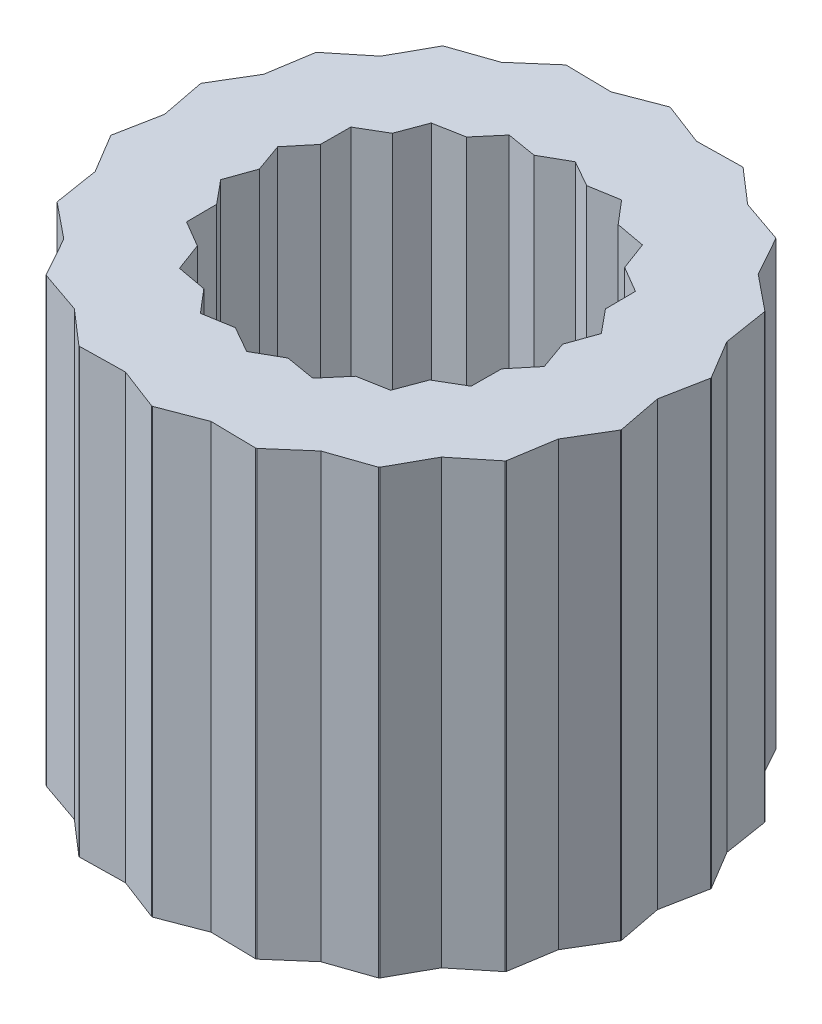
from build123d import *

# Parameters (mm, degrees)
BOSS_EXTRUDE1_DEPTH = 7
SKETCH2_R           = 5.515074568
SKETCH2_R_2         = 4.096991853
CUT_EXTRUDE1_DEPTH  = 10


with BuildPart() as part:
    # Sketch1 → Boss-Extrude1 (new body)
    with BuildSketch(Plane(origin=(0, 0, 0), x_dir=(1, 0, 0), z_dir=(0, 1, 0))):
        Polygon((0, 4.1), (-0.677227893, 3.840750237), (-1.402282588, 3.852739745), (-1.95, 3.377499075), (-2.6354292, 3.140782217), (-2.987573328, 2.506871678), (-3.550704156, 2.05), (-3.664801221, 1.333878559), (-4.037711787, 0.711957528), (-3.9, 0), (-4.037711787, -0.711957528), (-3.664801221, -1.333878559), (-3.550704156, -2.05), (-2.987573328, -2.506871678), (-2.6354292, -3.140782217), (-1.95, -3.377499075), (-1.402282588, -3.852739745), (-0.677227893, -3.840750237), (0, -4.1), (0.677227893, -3.840750237), (1.402282588, -3.852739745), (1.95, -3.377499075), (2.6354292, -3.140782217), (2.987573328, -2.506871678), (3.550704156, -2.05), (3.664801221, -1.333878559), (4.037711787, -0.711957528), (3.9, 0), (4.037711787, 0.711957528), (3.664801221, 1.333878559), (3.550704156, 2.05), (2.987573328, 2.506871678), (2.6354292, 3.140782217), (1.95, 3.377499075), (1.402282588, 3.852739745), (0.677227893, 3.840750237), align=None)
        Polygon((0, 2.6), (-0.416755626, 2.363538607), (-0.889252373, 2.443200814), (-1.2, 2.078460969), (-1.671247785, 1.991715552), (-1.838506663, 1.542690263), (-2.25166605, 1.3), (-2.25526229, 0.820848344), (-2.560500158, 0.451485262), (-2.4, 0), (-2.560500158, -0.451485262), (-2.25526229, -0.820848344), (-2.25166605, -1.3), (-1.838506663, -1.542690263), (-1.671247785, -1.991715552), (-1.2, -2.078460969), (-0.889252373, -2.443200814), (-0.416755626, -2.363538607), (0, -2.6), (0.416755626, -2.363538607), (0.889252373, -2.443200814), (1.2, -2.078460969), (1.671247785, -1.991715552), (1.838506663, -1.542690263), (2.25166605, -1.3), (2.25526229, -0.820848344), (2.560500158, -0.451485262), (2.4, 0), (2.560500158, 0.451485262), (2.25526229, 0.820848344), (2.25166605, 1.3), (1.838506663, 1.542690263), (1.671247785, 1.991715552), (1.2, 2.078460969), (0.889252373, 2.443200814), (0.416755626, 2.363538607), align=None, mode=Mode.SUBTRACT)
    extrude(amount=BOSS_EXTRUDE1_DEPTH)

    # Sketch2 → Cut-Extrude1 (cut)
    with BuildSketch(Plane(origin=(0, 7, 0), x_dir=(1, 0, 0), z_dir=(0, 1, 0))):
        Circle(SKETCH2_R)
        Circle(SKETCH2_R_2, mode=Mode.SUBTRACT)
    extrude(amount=-CUT_EXTRUDE1_DEPTH, mode=Mode.SUBTRACT)


solid = part.part
